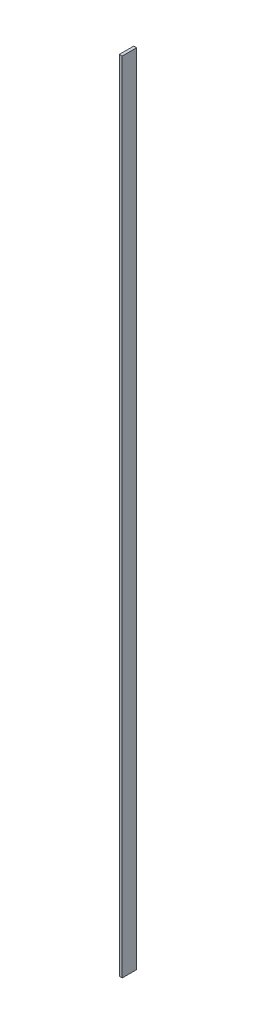
from build123d import *

# Parameters (mm, degrees)
SKETCH_1_W      = 4
SKETCH_1_H      = 20
EXTRUDE_1_DEPTH = 1100


with BuildPart() as part:
    # Эскиз1 → Бобышка-Вытянуть1 (new body)
    with BuildSketch(Plane(origin=(0, 0, 0), x_dir=(1, 0, 0), z_dir=(0, 1, 0))):
        Rectangle(SKETCH_1_W, SKETCH_1_H)
    extrude(amount=EXTRUDE_1_DEPTH)


solid = part.part
